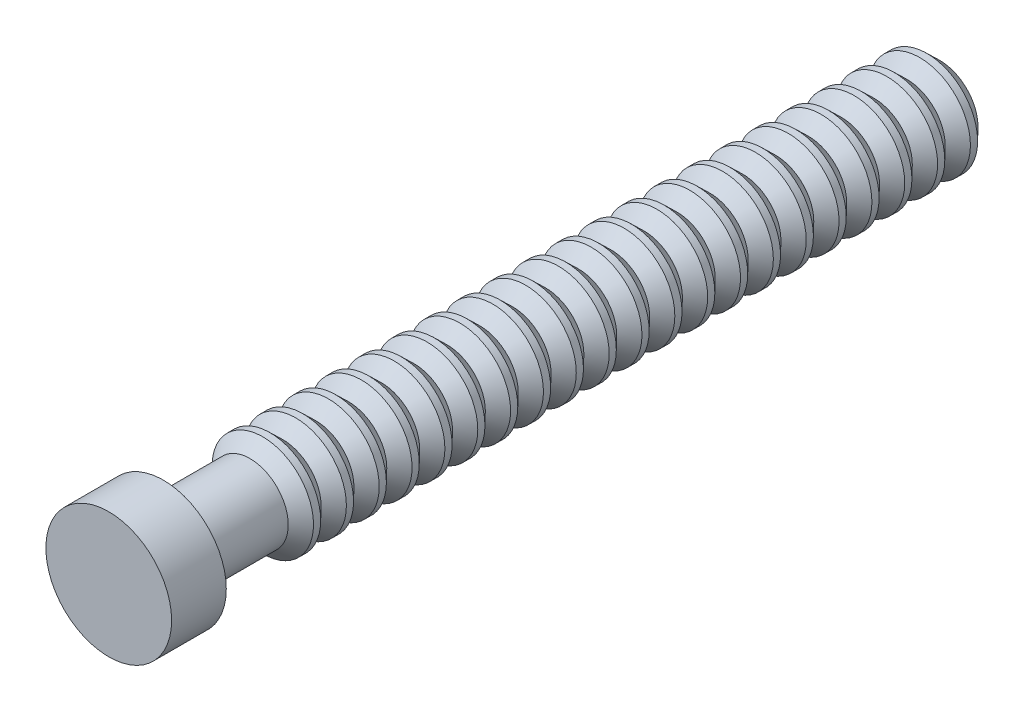
from build123d import *

# Parameters (mm, degrees)
SKETCH1_R           = 7.3025
BOSS_EXTRUDE1_DEPTH = 6.35
SKETCH2_R           = 4.445
BOSS_EXTRUDE2_DEPTH = 90.17


with BuildPart() as part:
    # Sketch1 → Boss-Extrude1 (new body)
    with BuildSketch(Plane.XY):
        Circle(SKETCH1_R)
    extrude(amount=BOSS_EXTRUDE1_DEPTH)

    # Sketch2 → Boss-Extrude2 (add)
    with BuildSketch(Plane.XY):
        Circle(SKETCH2_R)
    extrude(amount=-BOSS_EXTRUDE2_DEPTH)

    # Sketch8 → Revolve2 (revolve)
    with BuildSketch(Plane(origin=(0, 0, 0), x_dir=(0, 0, -1), z_dir=(1, 0, 0))):
        Polygon((10.053866594, 4.445), (13.868978205, 4.445), (12.376730728, 5.890229165), (11.54322298, 5.890229165), align=None)
        Polygon((86.357441717, 4.447477676), (86.35496404, 4.445), (90.17, 4.445), (88.677752523, 5.890229165), (87.844244775, 5.890229165), align=None)
        Polygon((84.032175557, 5.890229165), (82.539928081, 4.445), (86.35496404, 4.445), (86.352486364, 4.447477676), (84.865683306, 5.890229165), align=None)
        Polygon((78.727369797, 4.447477676), (78.724892121, 4.445), (82.539928081, 4.445), (81.047680604, 5.890229165), (80.214172856, 5.890229165), align=None)
        Polygon((76.402103638, 5.890229165), (74.909856162, 4.445), (78.724892121, 4.445), (78.722414445, 4.447477676), (77.235611386, 5.890229165), align=None)
        Polygon((71.097297878, 4.447477676), (71.094820202, 4.445), (74.909856162, 4.445), (73.417608685, 5.890229165), (72.584100937, 5.890229165), align=None)
        Polygon((68.772031719, 5.890229165), (67.279784243, 4.445), (71.094820202, 4.445), (71.092342526, 4.447477676), (69.605539467, 5.890229165), align=None)
        Polygon((64.954029018, 5.890229165), (63.464672632, 4.445), (67.279784243, 4.445), (65.787536766, 5.890229165), align=None)
        Polygon((61.141808498, 5.890229165), (59.649561022, 4.445), (63.464672632, 4.445), (61.975316246, 5.890229165), align=None)
        Polygon((55.837002738, 4.447477676), (55.834525062, 4.445), (59.649561022, 4.445), (58.157313545, 5.890229165), (57.323805797, 5.890229165), align=None)
        Polygon((53.511736579, 5.890229165), (52.019489102, 4.445), (55.834525062, 4.445), (55.832047386, 4.447477676), (54.345244327, 5.890229165), align=None)
        Polygon((49.693733878, 5.890229165), (48.204377492, 4.445), (52.019489102, 4.445), (50.527241626, 5.890229165), align=None)
        Polygon((45.881513358, 5.890229165), (44.389265881, 4.445), (48.204377492, 4.445), (46.715021106, 5.890229165), align=None)
        Polygon((40.576707598, 4.447477676), (40.574229922, 4.445), (44.389265881, 4.445), (42.897018405, 5.890229165), (42.063510657, 5.890229165), align=None)
        Polygon((38.251441439, 5.890229165), (36.759193962, 4.445), (40.574229922, 4.445), (40.571752246, 4.447477676), (39.084949187, 5.890229165), align=None)
        Polygon((32.946635679, 4.447477676), (32.944158003, 4.445), (36.759193962, 4.445), (35.266946486, 5.890229165), (34.433438737, 5.890229165), align=None)
        Polygon((30.62136952, 5.890229165), (29.129122043, 4.445), (32.944158003, 4.445), (32.941680327, 4.447477676), (31.454877268, 5.890229165), align=None)
        Polygon((25.31656376, 4.447477676), (25.314086083, 4.445), (29.129122043, 4.445), (27.636874566, 5.890229165), (26.803366818, 5.890229165), align=None)
        Polygon((22.991297601, 5.890229165), (21.499050124, 4.445), (25.314086083, 4.445), (25.311608407, 4.447477676), (23.824805349, 5.890229165), align=None)
        Polygon((17.68649184, 4.447477676), (17.684014164, 4.445), (21.499050124, 4.445), (20.006802647, 5.890229165), (19.173294899, 5.890229165), align=None)
        Polygon((15.361225681, 5.890229165), (13.868978205, 4.445), (17.684014164, 4.445), (17.681536488, 4.447477676), (16.19473343, 5.890229165), align=None)
    revolve(axis=Axis((0, 0, -90.17), (0, 0, -1)))


solid = part.part
